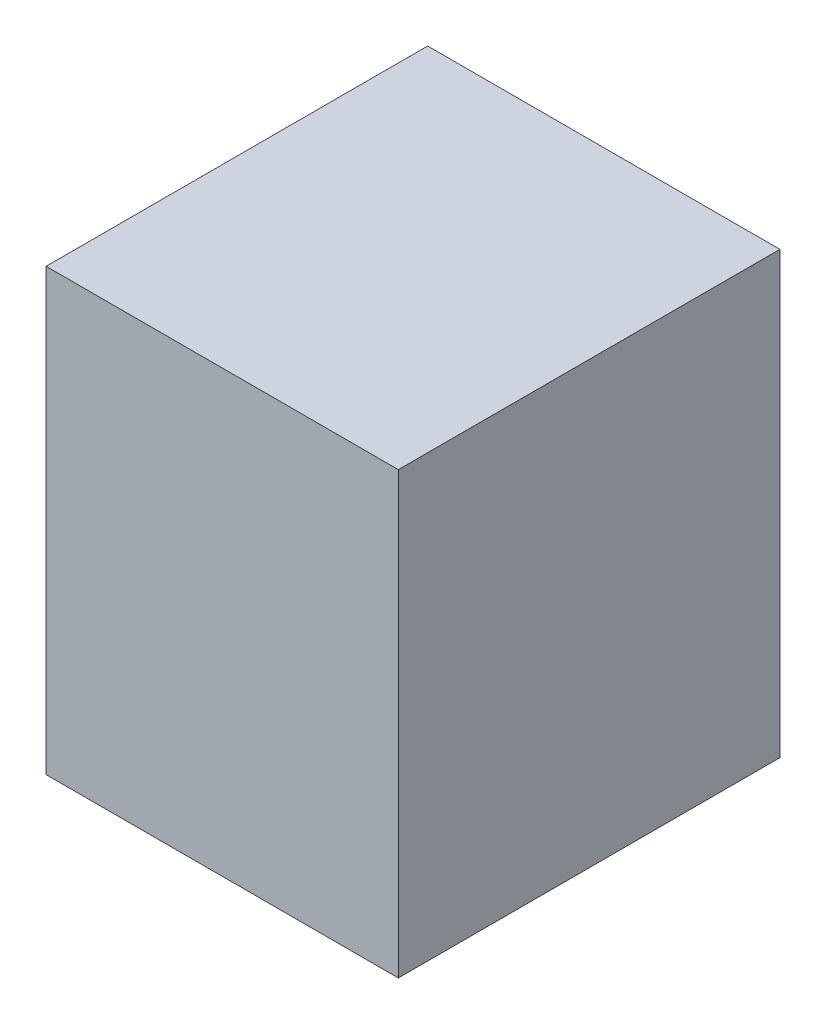
from build123d import *

# Parameters (mm, degrees)
SKETCH1_W           = 12
SKETCH1_H           = 15
BOSS_EXTRUDE1_DEPTH = 13
CUT_EXTRUDE1_DEPTH  = 8


with BuildPart() as part:
    # Sketch1 → Boss-Extrude1 (new body)
    with BuildSketch(Plane.XY):
        Rectangle(SKETCH1_W, SKETCH1_H)
    extrude(amount=BOSS_EXTRUDE1_DEPTH)

    # Sketch2 → Cut-Extrude1 (cut)
    with BuildSketch(Plane.XY):
        Polygon((1.331268312, 6.434952315), (-1.331268312, 6.434952315), (-1.331268312, 5.674031135), (-2.949806732, 5.674031135), (-2.949806732, 4.197823958), (-5.051214446, 4.197823958), (-5.051214446, -7.5), (5.051214446, -7.5), (5.051214446, 4.197823958), (2.949806732, 4.197823958), (2.949806732, 5.674031135), (1.331268312, 5.674031135), align=None)
    extrude(amount=CUT_EXTRUDE1_DEPTH, mode=Mode.SUBTRACT)


solid = part.part
